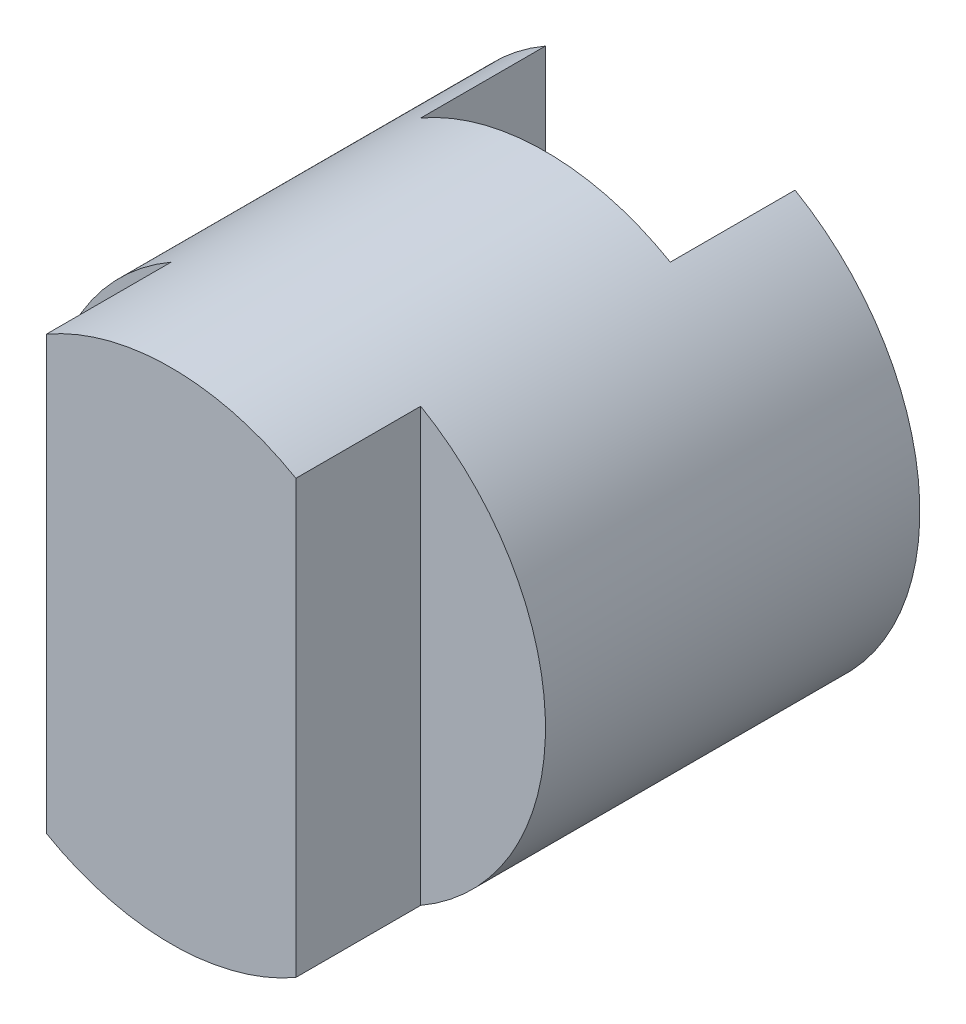
from build123d import *

# Parameters (mm, degrees)
SKETCH1_R           = 2
BOSS_EXTRUDE1_DEPTH = 4
SKETCH2_W           = 2
SKETCH2_H           = 0.99968346
CUT_EXTRUDE1_DEPTH  = 5


with BuildPart() as part:
    # Sketch1 → Boss-Extrude1 (new body)
    with BuildSketch(Plane.XY):
        Circle(SKETCH1_R)
    extrude(amount=BOSS_EXTRUDE1_DEPTH)

    # Sketch2 → Cut-Extrude1 (cut, symmetric)
    with BuildSketch(Plane(origin=(0, 0, 0), x_dir=(1, 0, 0), z_dir=(0, 1, 0))):
        Polygon((2, -3), (1, -3), (1, -4.221507546), (-1, -4.26455627), (-1, -3), (-2.31386892, -3), (-2.489753088, -4.306979917), (2, -4.619024092), (2.554571986, -4.221507546), align=None)
        with Locations((0, -0.49984173)):
            Rectangle(SKETCH2_W, SKETCH2_H)
    extrude(amount=CUT_EXTRUDE1_DEPTH, both=True, mode=Mode.SUBTRACT)


solid = part.part
